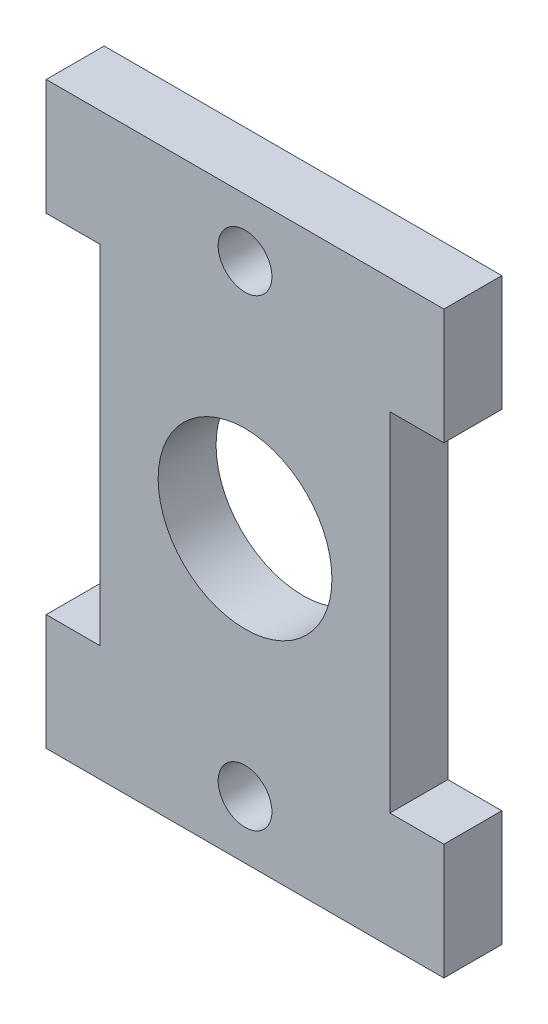
from build123d import *

# Parameters (mm, degrees)
BOSS_EXTRUDE1_DEPTH       = 3.175
F_4_CLEARANCE_HOLE1_D     = 2.9464
F_4_CLEARANCE_HOLE1_DEPTH = 3.302
F_4_CLEARANCE_HOLE1_TIP   = 0.885187864
CUT_EXTRUDE1_REACH        = 5.175
SKETCH4_R                 = 4.7625


with BuildPart() as part:
    # Sketch1 → Boss-Extrude1 (new body)
    with BuildSketch(Plane.XY):
        Polygon((7.9375, -3.175), (10.8966, -3.175), (10.8966, 3.175), (-10.8966, 3.175), (-10.8966, -3.175), (-7.9375, -3.175), (-7.9375, -22.225), (-10.8966, -22.225), (-10.8966, -28.575), (10.8966, -28.575), (10.8966, -22.225), (7.9375, -22.225), align=None)
    extrude(amount=BOSS_EXTRUDE1_DEPTH)

    # #4 Clearance Hole1
    with Locations(Plane.XY.offset(3.175)):
        with Locations((0, 0), (0, -25.4)):
            Hole(F_4_CLEARANCE_HOLE1_D / 2, depth=F_4_CLEARANCE_HOLE1_DEPTH)
            with Locations((0, 0, -(F_4_CLEARANCE_HOLE1_DEPTH + F_4_CLEARANCE_HOLE1_TIP / 2))):  # 118° drill point
                Cone(0, F_4_CLEARANCE_HOLE1_D / 2, F_4_CLEARANCE_HOLE1_TIP, mode=Mode.SUBTRACT)

    # Sketch4 → Cut-Extrude1 (cut, up to next)
    with BuildSketch(Plane.XY.offset(3.175), mode=Mode.PRIVATE) as cut_extrude1_sk1:
        with Locations((0, -12.7)):
            Circle(SKETCH4_R)
    cut_extrude1_tool1 = extrude(cut_extrude1_sk1.sketch, amount=-CUT_EXTRUDE1_REACH, mode=Mode.PRIVATE) & part.part
    add(cut_extrude1_tool1.solids().sort_by_distance((0, -12.7, 3.175))[0], mode=Mode.SUBTRACT)


solid = part.part
